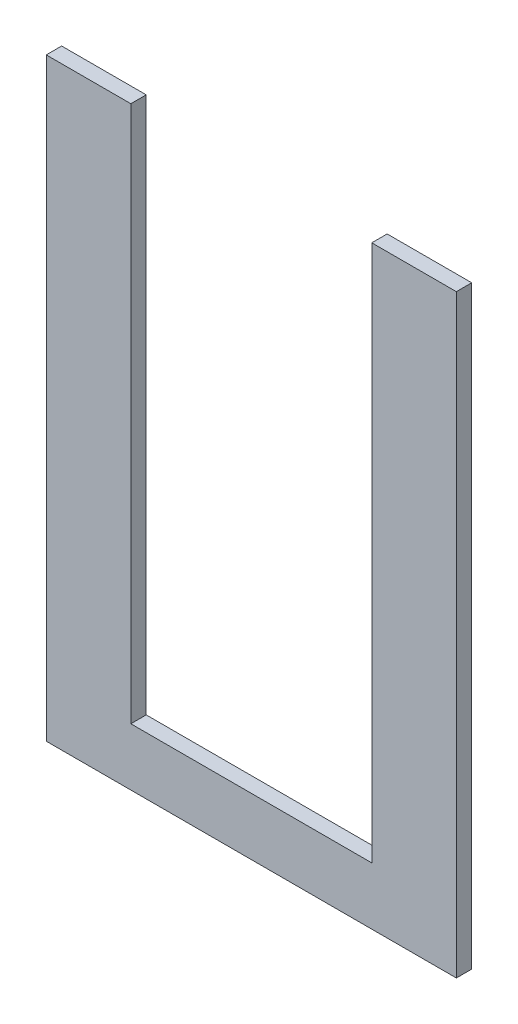
from build123d import *

# Parameters (mm, degrees)
BOSS_EXTRUDE1_DEPTH = 3


with BuildPart() as part:
    # Sketch1 → Boss-Extrude1 (new body)
    with BuildSketch(Plane.XY):
        Polygon((0, 0), (80, 0), (80, 115.957009142), (63.5, 115.957009142), (63.5, 11.2), (16.5, 11.2), (16.5, 115.957009142), (0, 115.957009142), align=None)
    extrude(amount=-BOSS_EXTRUDE1_DEPTH)


solid = part.part
